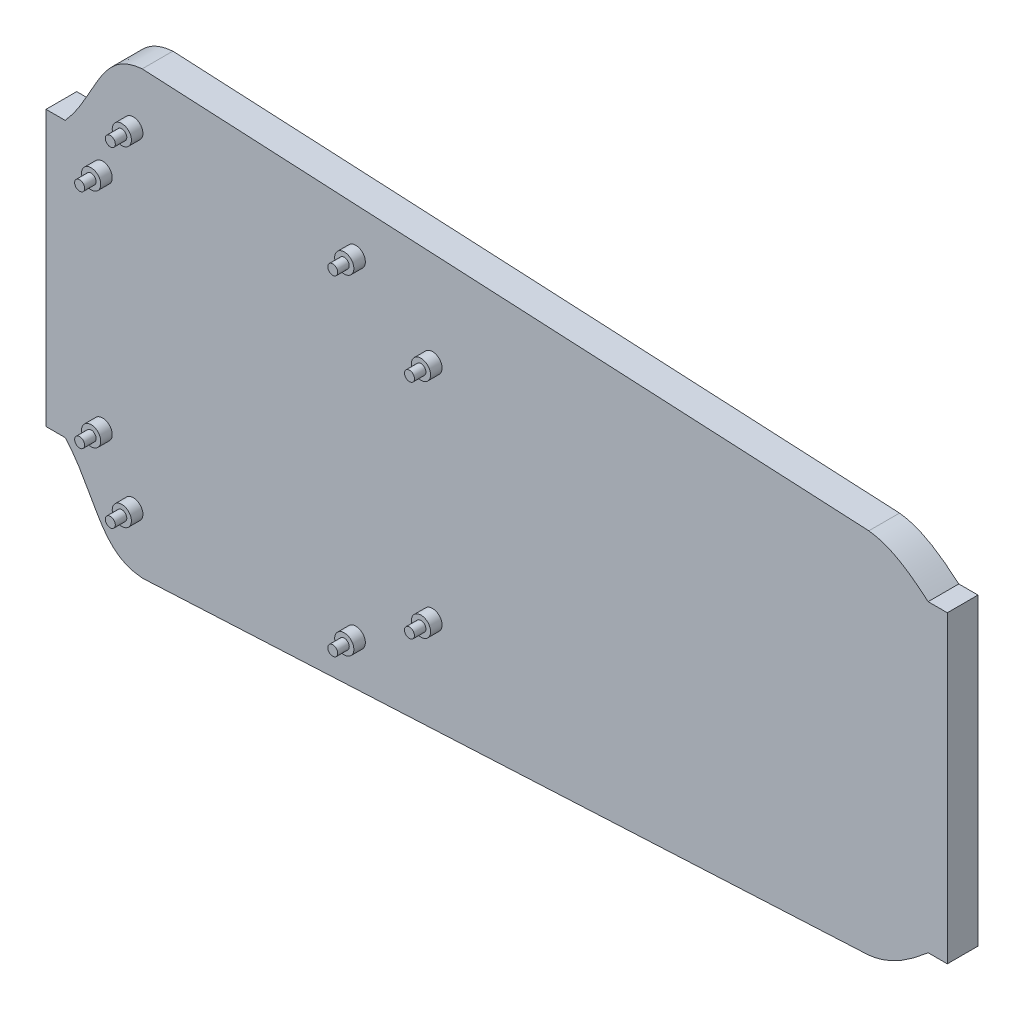
from build123d import *

# Parameters (mm, degrees)
BOSS_EXTRUDE1_DEPTH = 8
SKETCH2_R           = 2.5
BOSS_EXTRUDE2_DEPTH = 3
SKETCH3_R           = 1.3
BOSS_EXTRUDE3_DEPTH = 3


with BuildPart() as part:
    # Sketch1 → Boss-Extrude1 (new body)
    with BuildSketch(Plane.XY):
        with BuildLine():
            Line((128.959100066, 33.628624999), (133.959100066, 33.628624999))
            Line((133.959100066, 33.628624999), (133.959100066, -45.656116492))
            Line((133.959100066, -45.656116492), (128.959100066, -45.656116492))
            add(Edge.make_bspline(
                [(113.496599029, -53.92747215), (114.973875685, -53.76034768), (116.389465073, -53.408303088), (118.438931288, -52.658652366), (119.109837198, -52.372048444), (120.430638868, -51.735858399), (121.082915856, -51.384782434), (122.988929436, -50.267489711), (124.197203446, -49.437169981), (126.541735842, -47.677906536), (127.677620036, -46.748450374), (128.850515141, -45.74891878), (128.904828159, -45.702543351), (128.959100066, -45.656116492)],
                knots=[0, 0, 0, 0, 0.125, 0.125, 0.1875, 0.1875, 0.25, 0.25, 0.375, 0.375, 0.5, 0.5, 0.506074438, 0.506074438, 0.506074438, 0.506074438], degree=3))
            Line((113.496599029, -53.92747215), (-75.963345356, -63.503442328))
            add(Edge.make_bspline(
                [(-96.040899934, -41.829259963), (-95.798899268, -42.093160096), (-95.56197213, -42.362136183), (-94.03954966, -44.156758027), (-92.923608678, -45.792412437), (-90.858487716, -49.170948695), (-89.911065512, -50.914960796), (-88.457766632, -53.51029646), (-87.967520262, -54.371999904), (-86.940892781, -56.06392928), (-86.404912323, -56.894254814), (-85.530671439, -58.091259413), (-85.227414802, -58.482089731), (-84.588818098, -59.241614046), (-84.254184704, -59.609132259), (-83.204929916, -60.651600397), (-82.440569541, -61.270576891), (-81.160629249, -62.042718444), (-80.719255742, -62.269433113), (-79.817314106, -62.660888928), (-79.3554021, -62.826549047), (-77.940467092, -63.243286827), (-76.954208328, -63.414201398), (-75.963345356, -63.503442328)],
                knots=[0.352672192, 0.352672192, 0.352672192, 0.352672192, 0.375, 0.375, 0.5, 0.5, 0.625, 0.625, 0.6875, 0.6875, 0.75, 0.75, 0.78125, 0.78125, 0.8125, 0.8125, 0.875, 0.875, 0.90625, 0.90625, 0.9375, 0.9375, 1, 1, 1, 1], degree=3))
            Line((-96.040899934, -41.829259963), (-101.040899934, -41.829259963))
            Line((-101.040899934, -41.829259963), (-101.040899934, 29.801740739))
            Line((-101.040899934, 29.801740739), (-96.040899934, 29.801740739))
            add(Edge.make_bspline(
                [(-75.963345356, 51.475952827), (-76.969760945, 51.385311169), (-77.956664013, 51.213742336), (-79.395866789, 50.78571401), (-79.86970863, 50.613871194), (-80.796837185, 50.204577199), (-81.240590365, 49.971323111), (-82.089787414, 49.449496549), (-82.495246976, 49.160946736), (-83.271465049, 48.533739024), (-83.643007435, 48.194375714), (-84.708444042, 47.116795042), (-85.333215001, 46.343374139), (-86.491296884, 44.737676097), (-87.023827607, 43.904896882), (-88.044872363, 42.211012893), (-88.533034054, 41.34968138), (-89.982900727, 38.756279626), (-90.93240726, 37.013628654), (-92.999467157, 33.650383947), (-94.114586107, 32.031232641), (-95.60337212, 30.287705281), (-95.819744565, 30.042891916), (-96.040899934, 29.801740739)],
                knots=[0, 0, 0, 0, 0.0625, 0.0625, 0.09375, 0.09375, 0.125, 0.125, 0.15625, 0.15625, 0.1875, 0.1875, 0.25, 0.25, 0.3125, 0.3125, 0.375, 0.375, 0.5, 0.5, 0.625, 0.625, 0.645748558, 0.645748558, 0.645748558, 0.645748558], degree=3))
            Line((-75.963345356, 51.475952827), (113.496599029, 41.899982649))
            add(Edge.make_bspline(
                [(128.959100066, 33.628624999), (128.913387154, 33.667730585), (127.751192536, 34.660386778), (126.568806099, 35.629041088), (124.805320754, 36.953884089), (124.207009004, 37.38378621), (122.992052543, 38.206145046), (122.374602128, 38.599251589), (120.484333172, 39.709851881), (119.174169326, 40.359663675), (117.093195419, 41.124643977), (116.387101294, 41.341482025), (114.957490187, 41.687263925), (114.232477088, 41.816732683), (113.496599029, 41.899982649)],
                knots=[0.494878569, 0.494878569, 0.494878569, 0.494878569, 0.5, 0.625, 0.625, 0.6875, 0.6875, 0.75, 0.75, 0.875, 0.875, 0.9375, 0.9375, 1, 1, 1, 1], degree=3))
        make_face()
    extrude(amount=BOSS_EXTRUDE1_DEPTH)

    # Sketch2 → Boss-Extrude2 (add)
    with BuildSketch(Plane.XY.offset(8)):
        with Locations((-86.273928885, 22.986240388)):
            Circle(SKETCH2_R)
        with Locations((-78.273928885, 36.986240388)):
            Circle(SKETCH2_R)
        with Locations((-20.273928885, 36.986240388)):
            Circle(SKETCH2_R)
        with Locations((-0.273928885, 22.986240388)):
            Circle(SKETCH2_R)
        with Locations((-0.273928885, -35.013759612)):
            Circle(SKETCH2_R)
        with Locations((-20.273928885, -49.013759612)):
            Circle(SKETCH2_R)
        with Locations((-78.273928885, -49.013759612)):
            Circle(SKETCH2_R)
        with Locations((-86.273928885, -35.013759612)):
            Circle(SKETCH2_R)
    extrude(amount=BOSS_EXTRUDE2_DEPTH)

    # Sketch3 → Boss-Extrude3 (add)
    with BuildSketch(Plane.XY.offset(11)):
        with Locations((-86.273928885, 22.986240388)):
            Circle(SKETCH3_R)
        with Locations((-78.273928885, 36.986240388)):
            Circle(SKETCH3_R)
        with Locations((-20.273928885, 36.986240388)):
            Circle(SKETCH3_R)
        with Locations((-0.273928885, 22.986240388)):
            Circle(SKETCH3_R)
        with Locations((-0.273928885, -35.013759612)):
            Circle(SKETCH3_R)
        with Locations((-20.273928885, -49.013759612)):
            Circle(SKETCH3_R)
        with Locations((-78.273928885, -49.013759612)):
            Circle(SKETCH3_R)
        with Locations((-86.273928885, -35.013759612)):
            Circle(SKETCH3_R)
    extrude(amount=BOSS_EXTRUDE3_DEPTH)


solid = part.part
